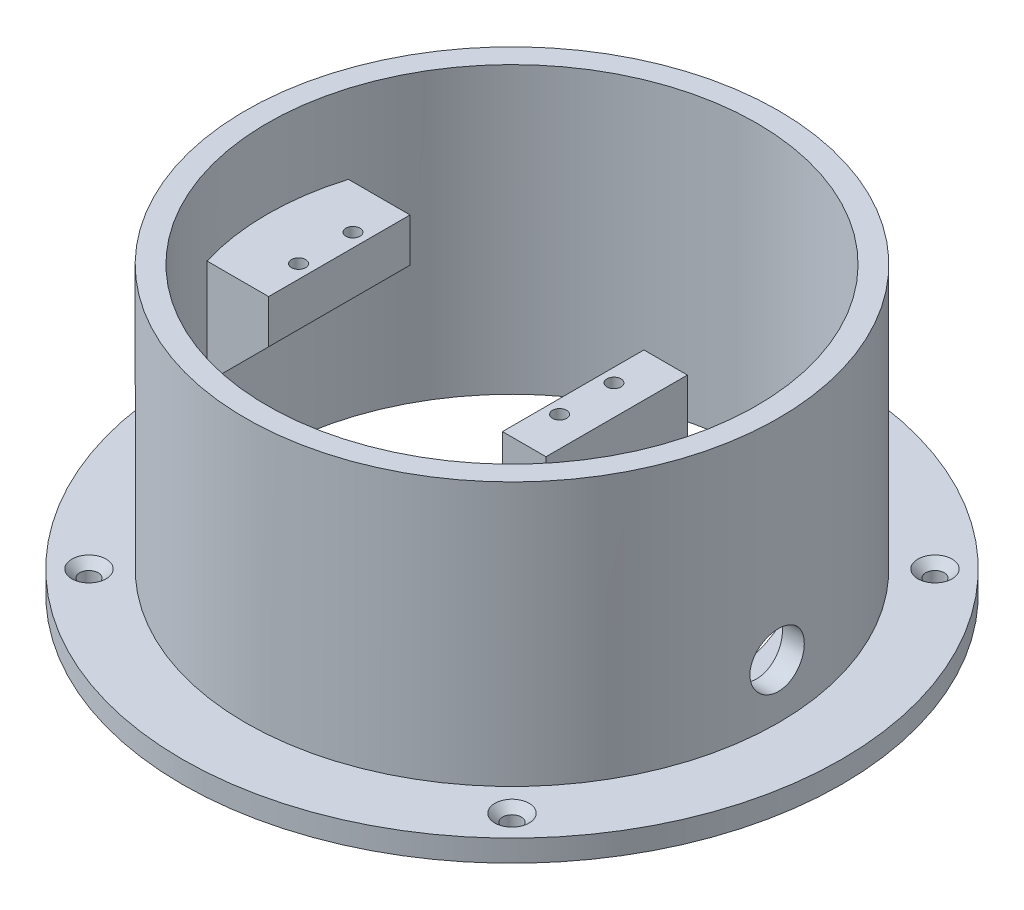
from build123d import *

# Parameters (mm, degrees)
SKETCH1_R                                           = 60.625
SKETCH1_R_2                                         = 45
BOSS_EXTRUDE1_DEPTH                                 = 4
SKETCH2_R                                           = 49
SKETCH2_R_2                                         = 45
BOSS_EXTRUDE2_DEPTH                                 = 52
SKETCH4_W                                           = 13.25
SKETCH4_H                                           = 8
SKETCH4_W_2                                         = 8
SKETCH4_H_2                                         = 38
BOSS_EXTRUDE4_DEPTH                                 = 13
BOSS_EXTRUDE5_DEPTH                                 = 4
SKETCH7_R                                           = 1.3
CUT_EXTRUDE4_DEPTH                                  = 7.2
SKETCH9_W                                           = 10
SKETCH9_H                                           = 24
CUT_EXTRUDE7_DEPTH                                  = 8
CUT_EXTRUDE8_REACH                                  = 111.625
SKETCH11_R                                          = 5
CUT_EXTRUDE9_DEPTH                                  = 5.0000001
CSK_FOR_M3_COUNTERSUNK_FLAT_HEAD_SCREW1_D           = 3.4
CSK_FOR_M3_COUNTERSUNK_FLAT_HEAD_SCREW1_DEPTH       = 4
CSK_FOR_M3_COUNTERSUNK_FLAT_HEAD_SCREW1_CSINK_D     = 6.3
CSK_FOR_M3_COUNTERSUNK_FLAT_HEAD_SCREW1_CSINK_ANGLE = 90
SKETCH18_W                                          = 98
SKETCH18_H                                          = 7
CUT_EXTRUDE10_DEPTH                                 = 61.625
CUT_EXTRUDE10_DEPTH_BACK                            = 61.625


with BuildPart() as part:
    # Sketch1 → Boss-Extrude1 (new body)
    with BuildSketch(Plane(origin=(0, 0, 0), x_dir=(1, 0, 0), z_dir=(0, 1, 0))):
        Circle(SKETCH1_R)
        Circle(SKETCH1_R_2, mode=Mode.SUBTRACT)
    extrude(amount=BOSS_EXTRUDE1_DEPTH)

    # Sketch2 → Boss-Extrude2 (add)
    with BuildSketch(Plane(origin=(0, 4, 0), x_dir=(1, 0, 0), z_dir=(0, 1, 0))):
        Circle(SKETCH2_R)
        Circle(SKETCH2_R_2, mode=Mode.SUBTRACT)
    extrude(amount=BOSS_EXTRUDE2_DEPTH)

    # Sketch4 → Boss-Extrude4 (add, symmetric)
    with BuildSketch(Plane.XY):
        with Locations((-38.375, 34)):
            Rectangle(SKETCH4_W, SKETCH4_H)
        Polygon((-31.75, 30), (-45, 30), (-45, 16.75), align=None)
        with Locations((15.25, 19)):
            Rectangle(SKETCH4_W_2, SKETCH4_H_2)
    extrude(amount=BOSS_EXTRUDE4_DEPTH, both=True)

    # Sketch5 → Boss-Extrude5 (add)
    with BuildSketch(Plane.XZ):
        with BuildLine():
            Line((11.25, 13), (29.067400866, 34.352382842))
            ThreePointArc((29.067400866, 34.352382842), (45, 0), (29.067400866, -34.352382842))
            Line((29.067400866, -34.352382842), (11.25, -13))
            Line((11.25, -13), (11.25, 13))
        make_face()
    extrude(amount=-BOSS_EXTRUDE5_DEPTH)

    # Sketch7 → Cut-Extrude4 (cut)
    with BuildSketch(Plane(origin=(0, 38, 0), x_dir=(1, 0, 0), z_dir=(0, 1, 0))):
        with Locations((-34.25, 5)):
            Circle(SKETCH7_R)
        with Locations((-34.25, -5)):
            Circle(SKETCH7_R)
        with Locations((13.75, 5)):
            Circle(SKETCH7_R)
        with Locations((13.75, -5)):
            Circle(SKETCH7_R)
    extrude(amount=-CUT_EXTRUDE4_DEPTH, mode=Mode.SUBTRACT)

    # Sketch9 → Cut-Extrude7 (cut)
    with BuildSketch(Plane.ZY.offset(-11.25)):
        with Locations((0, 17)):
            Rectangle(SKETCH9_W, SKETCH9_H)
    extrude(amount=-CUT_EXTRUDE7_DEPTH, mode=Mode.SUBTRACT)

    # Sketch11 → Cut-Extrude8 (cut, up to next)
    with BuildSketch(Plane(origin=(49, 0, 0), x_dir=(0, 0, -1), z_dir=(1, 0, 0)), mode=Mode.PRIVATE) as cut_extrude8_sk1:
        with Locations((0, 14)):
            Circle(SKETCH11_R)
    cut_extrude8_tool1 = extrude(cut_extrude8_sk1.sketch, amount=-CUT_EXTRUDE8_REACH, mode=Mode.PRIVATE) & part.part
    add(cut_extrude8_tool1.solids().sort_by_distance((49, 14, 0))[0], mode=Mode.SUBTRACT)

    # Sketch12 → Cut-Extrude9 (cut, through all)
    with BuildSketch(Plane(origin=(0, 4, 0), x_dir=(1, 0, 0), z_dir=(0, 1, 0))):
        with BuildLine():
            Line((29.479537487, 22.359715328), (27.25, 19.687836398))
            Line((27.25, 19.687836398), (27.25, -19.687836398))
            Line((27.25, -19.687836398), (29.479537487, -22.359715328))
            ThreePointArc((29.479537487, -22.359715328), (37, 0), (29.479537487, 22.359715328))
        make_face()
        Polygon((27.25, -19.687836398), (27.25, 19.687836398), (24.25, 16.092634774), (24.25, -16.092634774), align=None)
    extrude(amount=-CUT_EXTRUDE9_DEPTH, mode=Mode.SUBTRACT)

    # CSK for M3 Countersunk Flat Head Screw1
    with Locations(Plane(origin=(0, 4, 0), x_dir=(1, 0, 0), z_dir=(0, 1, 0))):
        with Locations((-38.890872965, 38.890872965), (-38.890872965, -38.890872965), (38.890872965, -38.890872965), (38.890872965, 38.890872965)):
            CounterSinkHole(CSK_FOR_M3_COUNTERSUNK_FLAT_HEAD_SCREW1_D / 2, CSK_FOR_M3_COUNTERSUNK_FLAT_HEAD_SCREW1_CSINK_D / 2, depth=CSK_FOR_M3_COUNTERSUNK_FLAT_HEAD_SCREW1_DEPTH, counter_sink_angle=CSK_FOR_M3_COUNTERSUNK_FLAT_HEAD_SCREW1_CSINK_ANGLE)

    # Sketch18 → Cut-Extrude10 (cut, two sides)
    with BuildSketch(Plane.XY) as cut_extrude10_sk:
        with Locations((0, 56)):
            Rectangle(SKETCH18_W, SKETCH18_H)
    extrude(amount=CUT_EXTRUDE10_DEPTH, mode=Mode.SUBTRACT)
    extrude(cut_extrude10_sk.sketch, amount=-CUT_EXTRUDE10_DEPTH_BACK, mode=Mode.SUBTRACT)


solid = part.part
